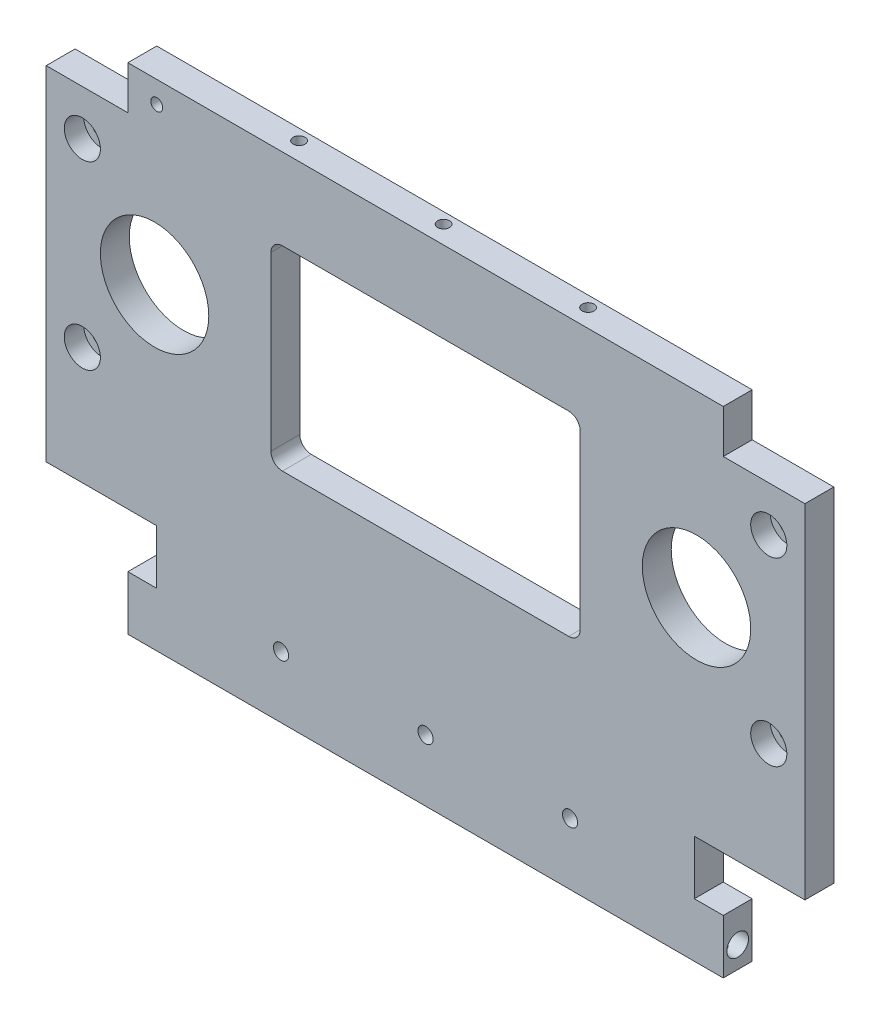
from build123d import *

# Parameters (mm, degrees)
SKETCH_1_W                   = 210
SKETCH_1_H                   = 75
EXTRUDE_1_DEPTH              = 8
CUT_EXTRUDE_1_DEPTH          = 9
HOLE_WIZARD_M5_1_D           = 5.5
HOLE_WIZARD_M5_1_DEPTH       = 10.1
HOLE_WIZARD_M5_1_CBORE_D     = 10
HOLE_WIZARD_M5_1_CBORE_DEPTH = 5.4
HOLE_WIZARD_M5_1_TIP         = 1.652366702
SKETCH_5_R                   = 15
CUT_EXTRUDE_2_DEPTH          = 13
SKETCH_6_W                   = 210
SKETCH_6_H                   = 8
EXTRUDE_2_DEPTH              = 50
SKETCH_7_W                   = 22.6
SKETCH_7_H                   = 30
CUT_EXTRUDE_3_DEPTH          = 20
SKETCH_9_R                   = 3
CUT_EXTRUDE_5_DEPTH          = 8
SKETCH_12_W                  = 164.8
SKETCH_12_H                  = 8
EXTRUDE_3_DEPTH              = 12
SKETCH_13_W                  = 8
SKETCH_13_H                  = 15
CUT_EXTRUDE_6_DEPTH          = 9
HOLE_WIZARD_M4_1_D           = 3.3
HOLE_WIZARD_M4_1_DEPTH       = 5
HOLE_WIZARD_M4_1_TIP         = 0.991420021
HOLE_WIZARD_M4_2_D           = 3.3
HOLE_WIZARD_M4_2_DEPTH       = 10.1
HOLE_WIZARD_M4_2_TIP         = 0.991420021
HOLE_WIZARD_M5_1_2_D         = 4.2
HOLE_WIZARD_M5_1_2_DEPTH     = 8
HOLE_WIZARD_M5_1_2_TIP       = 1.2618073
HOLE_WIZARD_M4_3_D           = 3.3
HOLE_WIZARD_M4_3_DEPTH       = 6
HOLE_WIZARD_M4_3_TIP         = 0.991420021


with BuildPart() as part:
    # 草图1 → 凸台-拉伸1 (new body)
    with BuildSketch(Plane.XY):
        with Locations((105, 37.5)):
            Rectangle(SKETCH_1_W, SKETCH_1_H)
    extrude(amount=EXTRUDE_1_DEPTH)

    # 草图2 → 切除-拉伸1 (cut, through all)
    with BuildSketch(Plane.XY.offset(8)):
        with BuildLine():
            Line((144.62, 64.5), (65.38, 64.5))
            ThreePointArc((65.38, 64.5), (63.131400436, 63.568599564), (62.2, 61.32))
            Line((62.2, 61.32), (62.2, 13.68))
            ThreePointArc((62.2, 13.68), (63.131400436, 11.431400436), (65.38, 10.5))
            Line((65.38, 10.5), (144.62, 10.5))
            ThreePointArc((144.62, 10.5), (146.868599564, 11.431400436), (147.8, 13.68))
            Line((147.8, 13.68), (147.8, 61.32))
            ThreePointArc((147.8, 61.32), (146.868599564, 63.568599564), (144.62, 64.5))
        make_face()
    extrude(amount=-CUT_EXTRUDE_1_DEPTH, mode=Mode.SUBTRACT)

    # Hole Wizard M5 _1
    with Locations(Plane.XY.offset(8)):
        with Locations((10, 62.5), (10, 12.5), (200, 62.5), (200, 12.5)):
            CounterBoreHole(HOLE_WIZARD_M5_1_D / 2, HOLE_WIZARD_M5_1_CBORE_D / 2, HOLE_WIZARD_M5_1_CBORE_DEPTH, depth=HOLE_WIZARD_M5_1_DEPTH)
            with Locations((0, 0, -(HOLE_WIZARD_M5_1_DEPTH + HOLE_WIZARD_M5_1_TIP / 2))):  # 118° drill point
                Cone(0, HOLE_WIZARD_M5_1_D / 2, HOLE_WIZARD_M5_1_TIP, mode=Mode.SUBTRACT)

    # 草图5 → 切除-拉伸2 (cut)
    with BuildSketch(Plane.XY.offset(8)):
        with Locations((30, 37.5)):
            Circle(SKETCH_5_R)
        with Locations((180, 37.5)):
            Circle(SKETCH_5_R)
    extrude(amount=-CUT_EXTRUDE_2_DEPTH, mode=Mode.SUBTRACT)

    # 草图6 → 凸台-拉伸2 (add)
    with BuildSketch(Plane.XZ):
        with Locations((105, 4)):
            Rectangle(SKETCH_6_W, SKETCH_6_H)
    extrude(amount=EXTRUDE_2_DEPTH)

    # 草图7 → 切除-拉伸3 (cut)
    with BuildSketch(Plane.XY.offset(8)):
        with Locations((11.3, -35)):
            Rectangle(SKETCH_7_W, SKETCH_7_H)
        with Locations((198.7, -35)):
            Rectangle(SKETCH_7_W, SKETCH_7_H)
    extrude(amount=-CUT_EXTRUDE_3_DEPTH, mode=Mode.SUBTRACT)

    # 草图9 → 切除-拉伸5 (cut)
    with BuildSketch(Plane.ZY.offset(-22.6)):
        with Locations((3.9960026, -44.027952664)):
            Circle(SKETCH_9_R)
    cut_extrude_5 = extrude(amount=-CUT_EXTRUDE_5_DEPTH, mode=Mode.SUBTRACT)

    # 镜向1: 切除-拉伸5 across plane
    add(cut_extrude_5.mirror(Plane.ZY.offset(-105)), mode=Mode.SUBTRACT)

    # 草图12 → 凸台-拉伸3 (add)
    with BuildSketch(Plane(origin=(0, 75, 0), x_dir=(1, 0, 0), z_dir=(0, 1, 0))):
        with Locations((105, -4)):
            Rectangle(SKETCH_12_W, SKETCH_12_H)
    extrude(amount=EXTRUDE_3_DEPTH)

    # 草图13 → 切除-拉伸6 (cut, through all)
    with BuildSketch(Plane.XY.offset(8)):
        with Locations((26.6, -27.5)):
            Rectangle(SKETCH_13_W, SKETCH_13_H)
        with Locations((183.4, -27.5)):
            Rectangle(SKETCH_13_W, SKETCH_13_H)
    extrude(amount=-CUT_EXTRUDE_6_DEPTH, mode=Mode.SUBTRACT)

    # M4 螺纹孔1
    with Locations(Plane(origin=(0, -50, 0), x_dir=(-1, 0, 0), z_dir=(0, -1, 0))):
        with Locations((-27.6, -4.002197451), (-182.4, -4.002197451)):
            Hole(HOLE_WIZARD_M4_1_D / 2, depth=HOLE_WIZARD_M4_1_DEPTH)
            with Locations((0, 0, -(HOLE_WIZARD_M4_1_DEPTH + HOLE_WIZARD_M4_1_TIP / 2))):  # 118° drill point
                Cone(0, HOLE_WIZARD_M4_1_D / 2, HOLE_WIZARD_M4_1_TIP, mode=Mode.SUBTRACT)

    # M4 螺纹孔2
    with Locations(Plane(origin=(0, 0, 0), x_dir=(-1, 0, 0), z_dir=(0, 0, -1))):
        with Locations((-30.6, 81)):
            Hole(HOLE_WIZARD_M4_2_D / 2, depth=HOLE_WIZARD_M4_2_DEPTH)
            with Locations((0, 0, -(HOLE_WIZARD_M4_2_DEPTH + HOLE_WIZARD_M4_2_TIP / 2))):  # 118° drill point
                Cone(0, HOLE_WIZARD_M4_2_D / 2, HOLE_WIZARD_M4_2_TIP, mode=Mode.SUBTRACT)

    # Hole Wizard M5 _1 2
    with Locations(Plane.XY.offset(8)):
        with Locations((65, -32.942976998), (105, -32.942976998), (145, -32.942976998)):
            Hole(HOLE_WIZARD_M5_1_2_D / 2, depth=HOLE_WIZARD_M5_1_2_DEPTH)
            with Locations((0, 0, -(HOLE_WIZARD_M5_1_2_DEPTH + HOLE_WIZARD_M5_1_2_TIP / 2))):  # 118° drill point
                Cone(0, HOLE_WIZARD_M5_1_2_D / 2, HOLE_WIZARD_M5_1_2_TIP, mode=Mode.SUBTRACT)

    # M4 螺纹孔3
    with Locations(Plane(origin=(0, 87, 0), x_dir=(1, 0, 0), z_dir=(0, 1, 0))):
        with Locations((145, -3), (105, -3), (65, -3)):
            Hole(HOLE_WIZARD_M4_3_D / 2, depth=HOLE_WIZARD_M4_3_DEPTH)
            with Locations((0, 0, -(HOLE_WIZARD_M4_3_DEPTH + HOLE_WIZARD_M4_3_TIP / 2))):  # 118° drill point
                Cone(0, HOLE_WIZARD_M4_3_D / 2, HOLE_WIZARD_M4_3_TIP, mode=Mode.SUBTRACT)


solid = part.part
